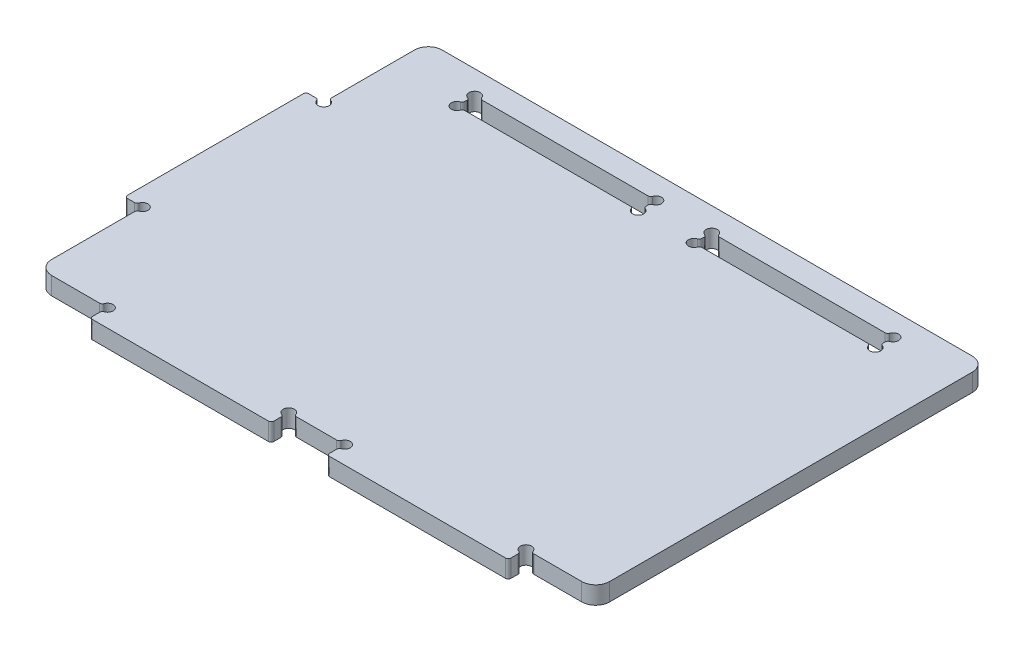
from build123d import *

# Parameters (mm, degrees)
SKETCH1_W              = 200
SKETCH1_H              = 140
BOSS_EXTRUDE1_DEPTH    = 6.35
SKETCH4_W              = 65
SKETCH4_H              = 6.35
BOSS_EXTRUDE2_DEPTH    = 6.35
LPATTERN1_COUNT        = 2
LPATTERN1_PITCH        = 85
SKETCH5_W              = 6.35
SKETCH5_H              = 65
BOSS_EXTRUDE3_DEPTH    = 6.35
SKETCH6_W              = 65
SKETCH6_H              = 6.35
CUT_EXTRUDE3_DEPTH     = 6.35
SKETCH7_R              = 2
CUT_EXTRUDE4_DEPTH     = 6.35
FILLET4_R              = 1
LPATTERN2_COUNT        = 2
LPATTERN2_PITCH        = 85
FILLET4_OF_LPATTERN2_R = 1
FILLET5_R              = 5
SKETCH8_R              = 2
CUT_EXTRUDE6_DEPTH     = 6.35
FILLET6_R              = 1


with BuildPart() as part:
    # Sketch1 → Boss-Extrude1 (new body)
    with BuildSketch(Plane(origin=(0, 0, 0), x_dir=(1, 0, 0), z_dir=(0, 1, 0))):
        Rectangle(SKETCH1_W, SKETCH1_H)
    extrude(amount=-BOSS_EXTRUDE1_DEPTH)

    # Sketch4 → Boss-Extrude2 (add)
    with BuildSketch(Plane(origin=(0, 0, 0), x_dir=(1, 0, 0), z_dir=(0, 1, 0))):
        with Locations((-42.5, -73.175)):
            Rectangle(SKETCH4_W, SKETCH4_H)
    boss_extrude2 = extrude(amount=-BOSS_EXTRUDE2_DEPTH)

    # LPattern1: Boss-Extrude2 ×2
    with Locations(*[(i * LPATTERN1_PITCH, 0, 0) for i in range(1, LPATTERN1_COUNT)]):
        add(boss_extrude2)

    # Sketch5 → Boss-Extrude3 (add)
    with BuildSketch(Plane(origin=(0, 0, 0), x_dir=(1, 0, 0), z_dir=(0, 1, 0))):
        with Locations((-103.175, 0)):
            Rectangle(SKETCH5_W, SKETCH5_H)
    extrude(amount=-BOSS_EXTRUDE3_DEPTH)

    # Sketch6 → Cut-Extrude3 (cut)
    with BuildSketch(Plane(origin=(0, 0, 0), x_dir=(1, 0, 0), z_dir=(0, 1, 0))):
        with Locations((42.5, 58.425)):
            Rectangle(SKETCH6_W, SKETCH6_H)
    cut_extrude3 = extrude(amount=-CUT_EXTRUDE3_DEPTH, mode=Mode.SUBTRACT)

    # Sketch7 → Cut-Extrude4 (cut)
    with BuildSketch(Plane(origin=(0, 0, 0), x_dir=(1, 0, 0), z_dir=(0, 1, 0))):
        with Locations((10, 55.25)):
            Circle(SKETCH7_R)
        with Locations((75, 55.25)):
            Circle(SKETCH7_R)
        with Locations((10, 61.6)):
            Circle(SKETCH7_R)
        with Locations((75, 61.6)):
            Circle(SKETCH7_R)
    cut_extrude4 = extrude(amount=-CUT_EXTRUDE4_DEPTH, mode=Mode.SUBTRACT)

    # Fillet4
    fillet4_edges = [part.edges().sort_by_distance(p)[0] for p in [
        (73, -3.175, -55.25),
        (12, -3.175, -55.25),
        (75, -3.175, -59.6),
        (12, -3.175, -61.6),
        (10, -3.175, -57.25),
        (73, -3.175, -61.6),
        (75, -3.175, -57.25),
        (10, -3.175, -59.6),
    ]]
    fillet(fillet4_edges, radius=FILLET4_R)

    # LPattern2: Cut-Extrude3, Cut-Extrude4 ×2
    with Locations(*[(-i * LPATTERN2_PITCH, 0, 0) for i in range(1, LPATTERN2_COUNT)]):
        add(cut_extrude3, mode=Mode.SUBTRACT)
        add(cut_extrude4, mode=Mode.SUBTRACT)

    # Fillet4 of LPattern2
    fillet4_of_lpattern2_edges = [part.edges().sort_by_distance(p)[0] for p in [
        (-12, -3.175, -55.25),
        (-73, -3.175, -55.25),
        (-10, -3.175, -59.6),
        (-73, -3.175, -61.6),
        (-75, -3.175, -57.25),
        (-12, -3.175, -61.6),
        (-10, -3.175, -57.25),
        (-75, -3.175, -59.6),
    ]]
    fillet(fillet4_of_lpattern2_edges, radius=FILLET4_OF_LPATTERN2_R)

    # Fillet5
    fillet5_edges = [part.edges().sort_by_distance(p)[0] for p in [
        (100, -3.175, 70),
        (-100, -3.175, 70),
        (-100, -3.175, -70),
        (100, -3.175, -70),
    ]]
    fillet(fillet5_edges, radius=FILLET5_R)

    # Sketch8 → Cut-Extrude6 (cut)
    with BuildSketch(Plane(origin=(0, 0, 0), x_dir=(1, 0, 0), z_dir=(0, 1, 0))):
        with Locations((-75, -70)):
            Circle(SKETCH8_R)
        with Locations((-10, -70)):
            Circle(SKETCH8_R)
        with Locations((10, -70)):
            Circle(SKETCH8_R)
        with Locations((75, -70)):
            Circle(SKETCH8_R)
        with Locations((-100, 32.5)):
            Circle(SKETCH8_R)
        with Locations((-100, -32.5)):
            Circle(SKETCH8_R)
    extrude(amount=-CUT_EXTRUDE6_DEPTH, mode=Mode.SUBTRACT)

    # Fillet6
    fillet6_edges = [part.edges().sort_by_distance(p)[0] for p in [
        (-75, -3.175, 76.35),
        (-10, -3.175, 76.35),
        (10, -3.175, 76.35),
        (75, -3.175, 76.35),
        (-102, -3.175, -32.5),
        (-102, -3.175, 32.5),
        (75, -3.175, 72),
        (10, -3.175, 72),
        (-10, -3.175, 72),
        (-75, -3.175, 72),
        (-100, -3.175, -34.5),
        (77, -3.175, 70),
        (8, -3.175, 70),
        (-8, -3.175, 70),
        (-100, -3.175, 34.5),
        (-77, -3.175, 70),
        (-106.35, -3.175, 32.5),
        (-106.35, -3.175, -32.5),
    ]]
    fillet(fillet6_edges, radius=FILLET6_R)


solid = part.part
